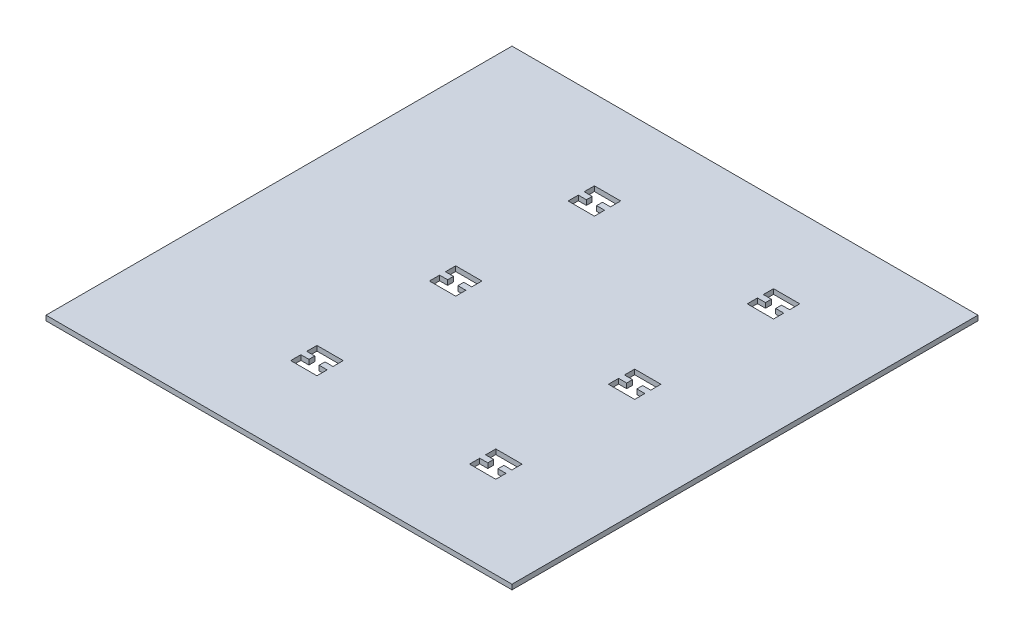
from build123d import *

# Parameters (mm, degrees)
SKETCH1_W           = 298.45
SKETCH1_H           = 298.45
BOSS_EXTRUDE1_DEPTH = 3.175


with BuildPart() as part:
    # Sketch1 → Boss-Extrude1 (new body)
    with BuildSketch(Plane(origin=(0, 0, 0), x_dir=(1, 0, 0), z_dir=(0, 1, 0))):
        Rectangle(SKETCH1_W, SKETCH1_H)
        Polygon((-45.662750287, -79.259778814), (-45.662750287, -85.799778814), (-40.519000287, -85.799778814), (-40.519000287, -89.547278814), (-45.662750287, -89.547278814), (-45.662750287, -96.087278814), (-28.835250287, -96.087278814), (-28.835250287, -89.547278814), (-33.979000287, -89.547278814), (-33.979000287, -85.799778814), (-28.835250287, -85.799778814), (-28.835250287, -79.259778814), align=None, mode=Mode.SUBTRACT)
        Polygon((-45.386244925, 9.311765916), (-45.386244925, 2.771765916), (-40.242494925, 2.771765916), (-40.242494925, -0.975734084), (-45.386244925, -0.975734084), (-45.386244925, -7.515734084), (-28.558744925, -7.515734084), (-28.558744925, -0.975734084), (-33.702494925, -0.975734084), (-33.702494925, 2.771765916), (-28.558744925, 2.771765916), (-28.558744925, 9.311765916), align=None, mode=Mode.SUBTRACT)
        Polygon((-45.346455929, 98.114077939), (-45.346455929, 91.574077939), (-40.202705929, 91.574077939), (-40.202705929, 87.826577939), (-45.346455929, 87.826577939), (-45.346455929, 81.286577939), (-28.518955929, 81.286577939), (-28.518955929, 87.826577939), (-33.662705929, 87.826577939), (-33.662705929, 91.574077939), (-28.518955929, 91.574077939), (-28.518955929, 98.114077939), align=None, mode=Mode.SUBTRACT)
        Polygon((69.069867305, 98.43417478), (69.069867305, 91.89417478), (74.213617305, 91.89417478), (74.213617305, 88.14667478), (69.069867305, 88.14667478), (69.069867305, 81.60667478), (85.897367305, 81.60667478), (85.897367305, 88.14667478), (80.753617305, 88.14667478), (80.753617305, 91.89417478), (85.897367305, 91.89417478), (85.897367305, 98.43417478), align=None, mode=Mode.SUBTRACT)
        Polygon((69.198133818, 9.367790367), (69.198133818, 2.827790367), (74.341883818, 2.827790367), (74.341883818, -0.919709633), (69.198133818, -0.919709633), (69.198133818, -7.459709633), (86.025633818, -7.459709633), (86.025633818, -0.919709633), (80.881883818, -0.919709633), (80.881883818, 2.827790367), (86.025633818, 2.827790367), (86.025633818, 9.367790367), align=None, mode=Mode.SUBTRACT)
        Polygon((69.012405726, -79.392168006), (69.012405726, -85.932168006), (74.156155726, -85.932168006), (74.156155726, -89.679668006), (69.012405726, -89.679668006), (69.012405726, -96.219668006), (85.839905726, -96.219668006), (85.839905726, -89.679668006), (80.696155726, -89.679668006), (80.696155726, -85.932168006), (85.839905726, -85.932168006), (85.839905726, -79.392168006), align=None, mode=Mode.SUBTRACT)
    extrude(amount=BOSS_EXTRUDE1_DEPTH)


solid = part.part
